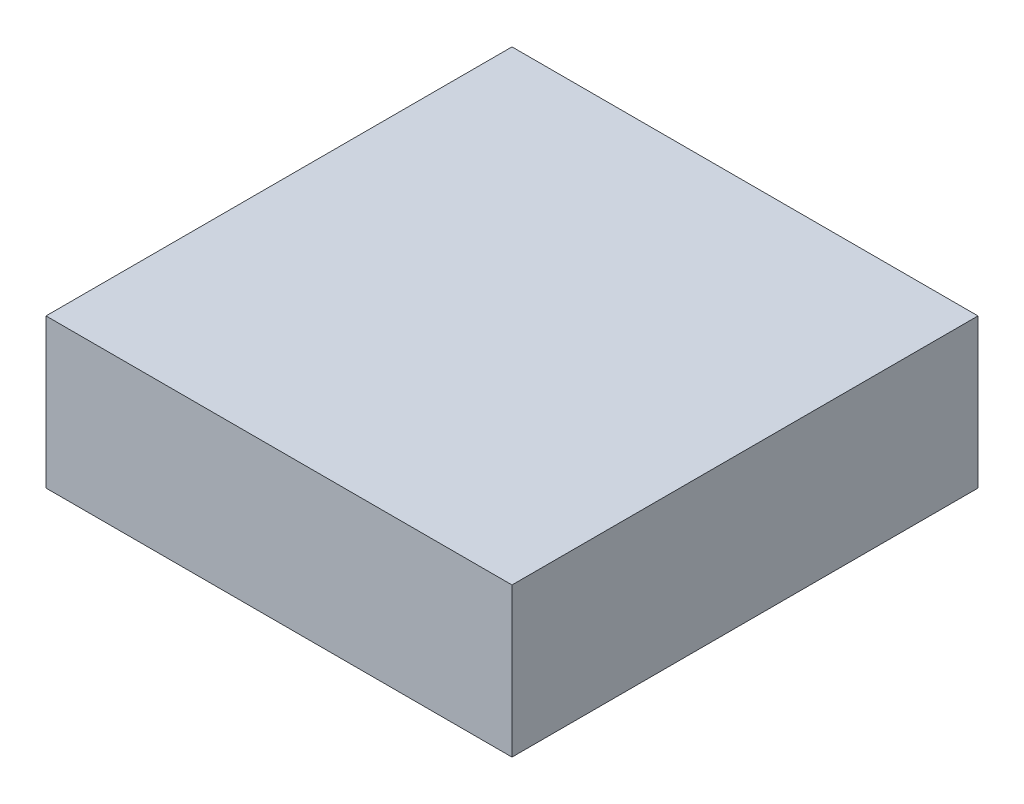
from build123d import *

# Parameters (mm, degrees)
BASES_W    = 2.5
BASES_H    = 2.5
BASE_DEPTH = 0.8


with BuildPart() as part:
    # BaseS → Base (new body)
    with BuildSketch(Plane(origin=(0, 0, 0), x_dir=(1, 0, 0), z_dir=(0, 1, 0))):
        Rectangle(BASES_W, BASES_H)
    extrude(amount=BASE_DEPTH)


solid = part.part
